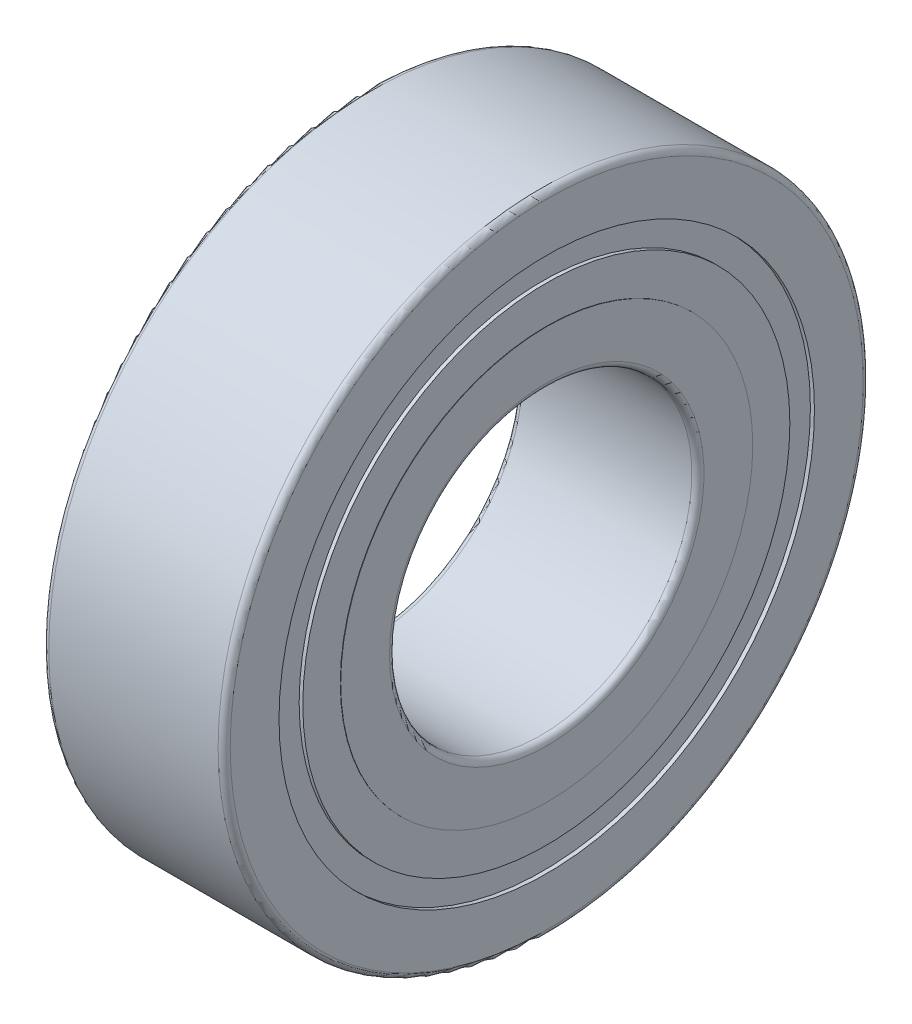
from build123d import *


with BuildPart() as part:
    # Sketch1 → Revolve1 (revolve)
    with BuildSketch(Plane.XY):
        with BuildLine():
            Line((-4.5, 15.7), (-4.5, 7.8))
            ThreePointArc((-4.5, 7.8), (-4.412132034, 7.587867966), (-4.2, 7.5))
            Line((-4.2, 7.5), (4.2, 7.5))
            ThreePointArc((4.2, 7.5), (4.412132034, 7.587867966), (4.5, 7.8))
            Line((4.5, 7.8), (4.5, 15.7))
            ThreePointArc((4.5, 15.7), (4.412132034, 15.912132034), (4.2, 16))
            Line((4.2, 16), (-4.2, 16))
            ThreePointArc((-4.2, 16), (-4.412132034, 15.912132034), (-4.5, 15.7))
        make_face()
    revolve(axis=Axis((50, 0, 0), (-1, 0, 0)))

    # Sketch2 → Cut-Revolve1 (revolve, cut)
    with BuildSketch(Plane.XY):
        Polygon((-6.3, 7.5), (-4.5, 7.5), (-4.5, 10.22), (-4.48, 10.22), (-4.48, 12.08), (-4.3, 12.08), (-4.3, 13.28), (-6.3, 13.28), align=None)
    revolve(axis=Axis((50, 0, 0), (-1, 0, 0)), mode=Mode.SUBTRACT)

    # Sketch3 → Cut-Revolve2 (revolve, cut)
    with BuildSketch(Plane.XY):
        Polygon((4.3, 13.28), (4.3, 12.08), (4.48, 12.08), (4.48, 10.22), (4.5, 10.22), (4.5, 7.5), (6.3, 7.5), (6.3, 13.28), align=None)
    revolve(axis=Axis((50, 0, 0), (-1, 0, 0)), mode=Mode.SUBTRACT)


solid = part.part
